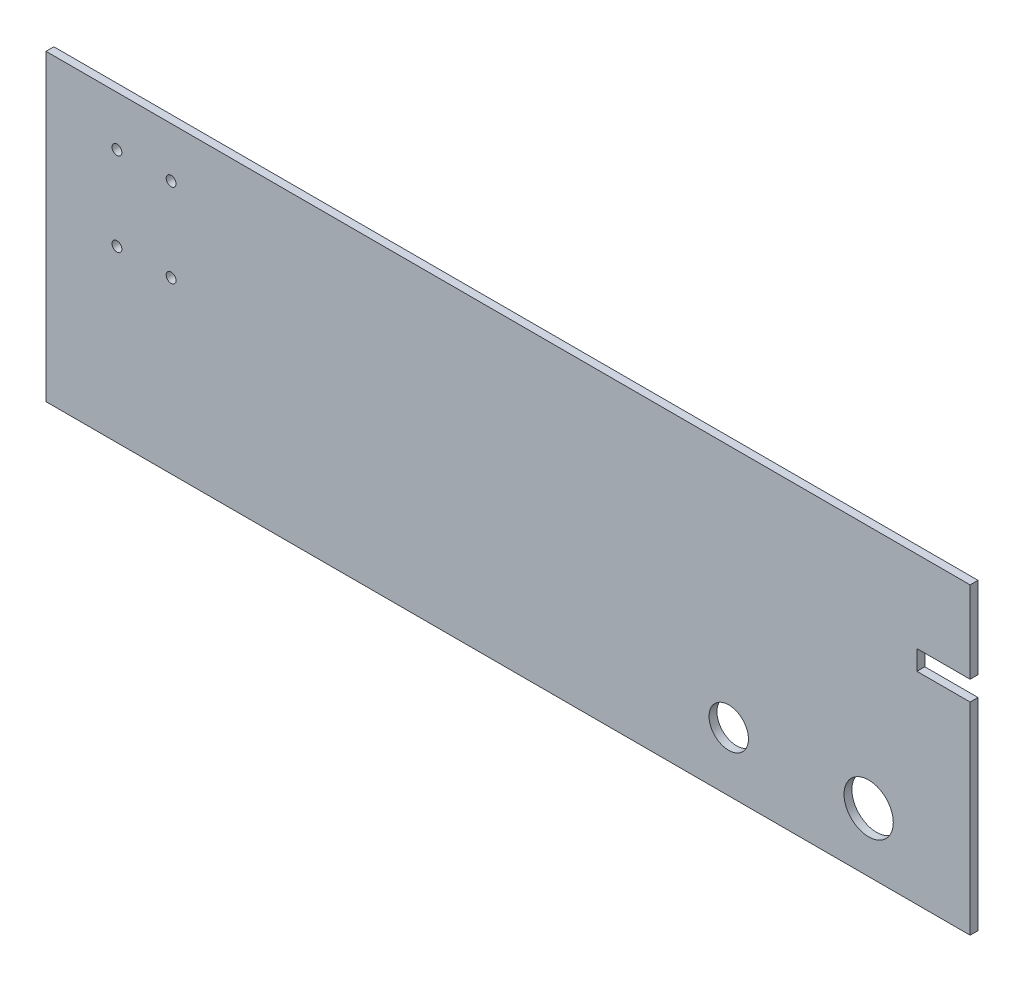
from build123d import *

# Parameters (mm, degrees)
ESQUISSEREF_R    = 20
ESQUISSEREF_R_2  = 5
ESQUISSEREF_R_3  = 25
EXTRUSION1_DEPTH = 8


with BuildPart() as part:
    # EsquisseRef → Extrusion1 (new body)
    with BuildSketch(Plane.XY):
        Polygon((-693, 248), (245, 248), (245, 165), (191, 165), (191, 145), (245, 145), (245, -60), (-693, -60), align=None)
        Circle(ESQUISSEREF_R, mode=Mode.SUBTRACT)
        with Locations((-621, 197.5)):
            Circle(ESQUISSEREF_R_2, mode=Mode.SUBTRACT)
        with Locations((-566, 197.5)):
            Circle(ESQUISSEREF_R_2, mode=Mode.SUBTRACT)
        with Locations((-566, 112.5)):
            Circle(ESQUISSEREF_R_2, mode=Mode.SUBTRACT)
        with Locations((-621, 112.5)):
            Circle(ESQUISSEREF_R_2, mode=Mode.SUBTRACT)
        with Locations((142, 0)):
            Circle(ESQUISSEREF_R_3, mode=Mode.SUBTRACT)
    extrude(amount=-EXTRUSION1_DEPTH)


solid = part.part
